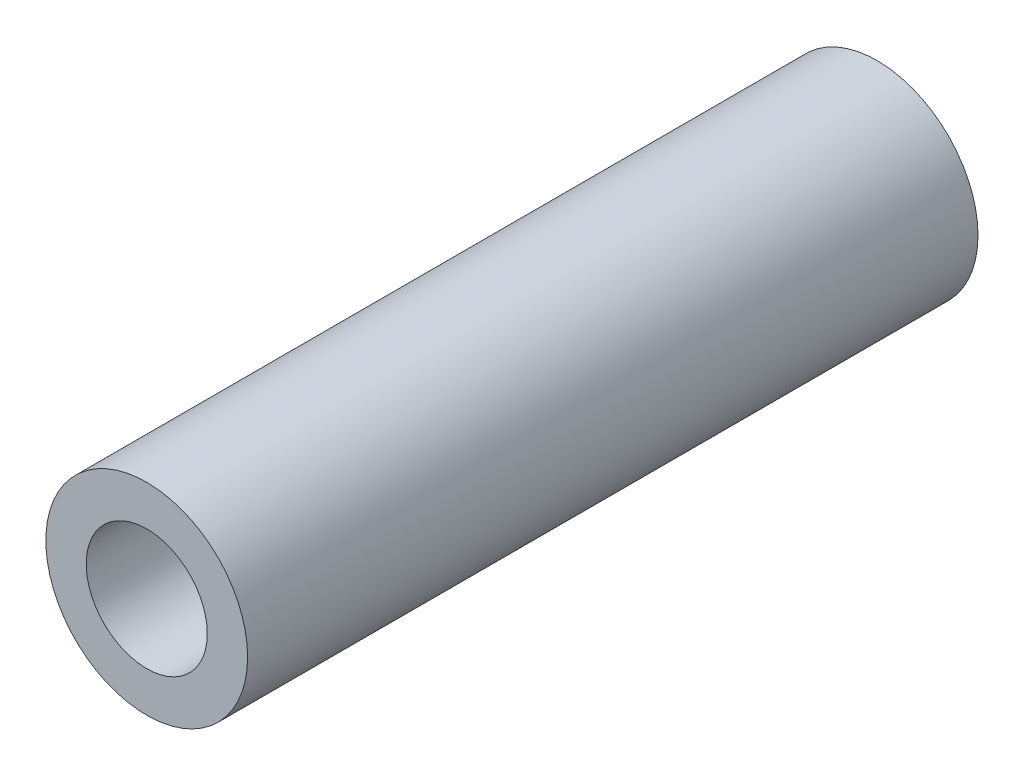
from build123d import *

# Parameters (mm, degrees)
SKETCH2_R           = 2.5
SKETCH2_R_2         = 1.5
BOSS_EXTRUDE1_DEPTH = 18.1


with BuildPart() as part:
    # Sketch2 → Boss-Extrude1 (new body)
    with BuildSketch(Plane.XY):
        Circle(SKETCH2_R)
        Circle(SKETCH2_R_2, mode=Mode.SUBTRACT)
    extrude(amount=BOSS_EXTRUDE1_DEPTH)


solid = part.part
